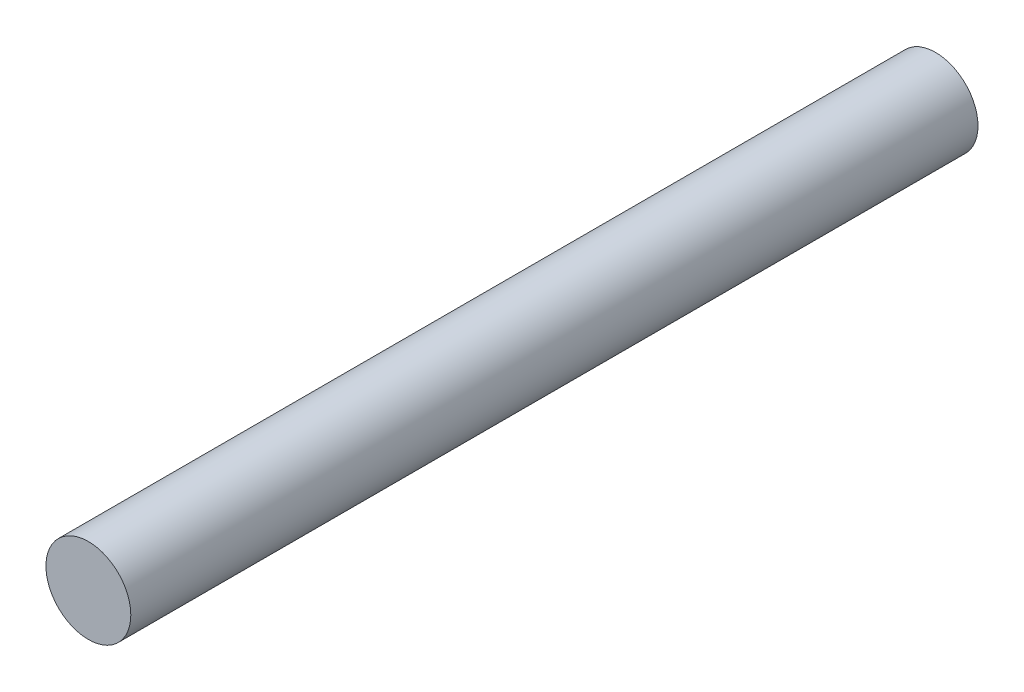
from build123d import *

# Parameters (mm, degrees)
SKETCH1_R           = 2.475
BOSS_EXTRUDE1_DEPTH = 50.45
CHAMFER1_SIZE       = 1.5
CHAMFER1_SIZE2      = 1.050311307


with BuildPart() as part:
    # Sketch1 → Boss-Extrude1 (new body)
    with BuildSketch(Plane.XY):
        Circle(SKETCH1_R)
    extrude(amount=BOSS_EXTRUDE1_DEPTH)

    # Chamfer1
    chamfer1_edges = [part.edges().sort_by_distance(p)[0] for p in [
        (-2.475, 0, 0),
    ]]
    chamfer1_side = [part.faces().sort_by_distance(p)[0] for p in [
        (0, 0, 0),
    ]]
    chamfer(chamfer1_edges, length=CHAMFER1_SIZE, length2=CHAMFER1_SIZE2, reference=chamfer1_side[0])


solid = part.part
